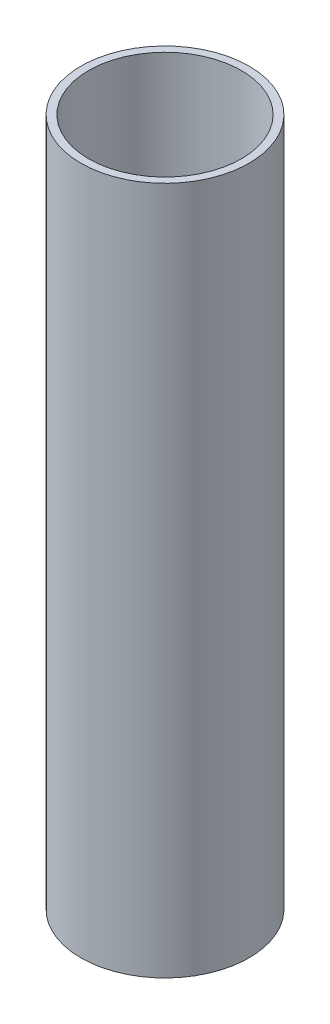
from build123d import *

# Parameters (mm, degrees)
SKETCH_1_R      = 11
SKETCH_1_R_2    = 10
EXTRUDE_1_DEPTH = 90


with BuildPart() as part:
    # 草图1 → 凸台-拉伸1 (new body)
    with BuildSketch(Plane(origin=(0, 0, 0), x_dir=(1, 0, 0), z_dir=(0, 1, 0))):
        Circle(SKETCH_1_R)
        Circle(SKETCH_1_R_2, mode=Mode.SUBTRACT)
    extrude(amount=EXTRUDE_1_DEPTH)


solid = part.part
